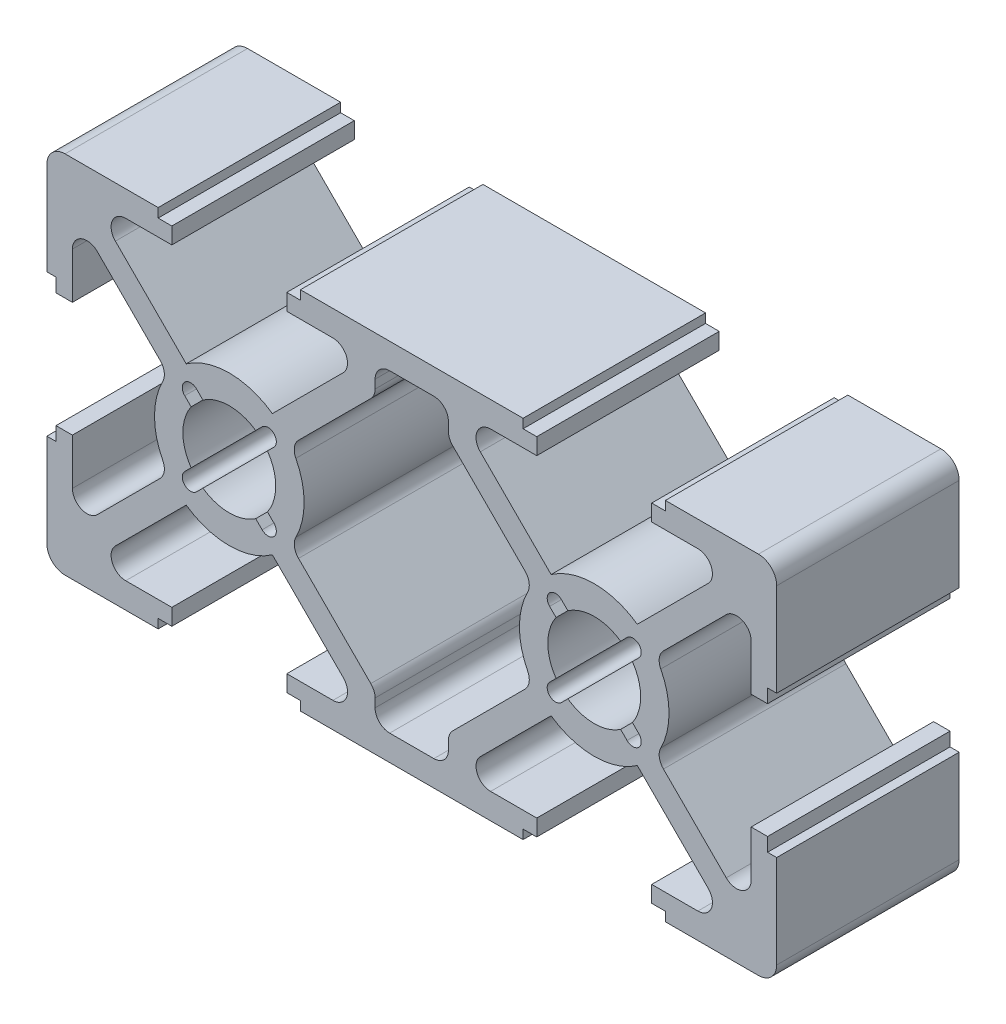
from build123d import *

# Parameters (mm, degrees)
Y_KSEKLIK_EKSTR_ZYON2_DEPTH = 10
RADYUS1_R                   = 0.8


with BuildPart() as part:
    # Çizim3 → Yükseklik-Ekstrüzyon2 (new body)
    with BuildSketch(Plane.XY):
        with BuildLine():
            Line((1, 0), (6.1, 0))
            Line((6.1, 0), (6.1, 0.5))
            Line((6.1, 0.5), (6.85, 0.5))
            Line((6.85, 0.5), (6.85, 1.4))
            Line((6.85, 1.4), (4.321320344, 1.4))
            ThreePointArc((4.321320344, 1.4), (3.582216718, 1.893853254), (3.755634919, 2.765685425))
            Line((3.755634919, 2.765685425), (7.638403375, 6.648453882))
            ThreePointArc((7.638403375, 6.648453882), (10, 5.9), (12.361596625, 6.648453882))
            Line((12.361596625, 6.648453882), (16.244365081, 2.765685425))
            ThreePointArc((16.244365081, 2.765685425), (16.417783282, 1.893853254), (15.678679656, 1.4))
            Line((15.678679656, 1.4), (13.15, 1.4))
            Line((13.15, 1.4), (13.15, 0.5))
            Line((13.15, 0.5), (13.9, 0.5))
            Line((13.9, 0.5), (13.9, 0))
            Line((13.9, 0), (26.1, 0))
            Line((26.1, 0), (26.1, 0.5))
            Line((26.1, 0.5), (26.85, 0.5))
            Line((26.85, 0.5), (26.85, 1.4))
            Line((26.85, 1.4), (24.321320344, 1.4))
            ThreePointArc((24.321320344, 1.4), (23.582216718, 1.893853254), (23.755634919, 2.765685425))
            Line((23.755634919, 2.765685425), (27.638403375, 6.648453882))
            ThreePointArc((27.638403375, 6.648453882), (30, 5.9), (32.361596625, 6.648453882))
            Line((32.361596625, 6.648453882), (36.244365081, 2.765685425))
            ThreePointArc((36.244365081, 2.765685425), (36.417783282, 1.893853254), (35.678679656, 1.4))
            Line((35.678679656, 1.4), (33.15, 1.4))
            Line((33.15, 1.4), (33.15, 0.5))
            Line((33.15, 0.5), (33.9, 0.5))
            Line((33.9, 0.5), (33.9, 0))
            Line((33.9, 0), (39, 0))
            ThreePointArc((39, 0), (39.707106781, 0.292893219), (40, 1))
            Line((40, 1), (40, 6.1))
            Line((40, 6.1), (39.5, 6.1))
            Line((39.5, 6.1), (39.5, 6.85))
            Line((39.5, 6.85), (38.6, 6.85))
            Line((38.6, 6.85), (38.6, 4.321320344))
            ThreePointArc((38.6, 4.321320344), (38.106146746, 3.582216718), (37.234314575, 3.755634919))
            Line((37.234314575, 3.755634919), (33.351546118, 7.638403375))
            ThreePointArc((33.351546118, 7.638403375), (34.1, 10), (33.351546118, 12.361596625))
            Line((33.351546118, 12.361596625), (37.234314575, 16.244365081))
            ThreePointArc((37.234314575, 16.244365081), (38.106146746, 16.417783282), (38.6, 15.678679656))
            Line((38.6, 15.678679656), (38.6, 13.15))
            Line((38.6, 13.15), (39.5, 13.15))
            Line((39.5, 13.15), (39.5, 13.9))
            Line((39.5, 13.9), (40, 13.9))
            Line((40, 13.9), (40, 19))
            ThreePointArc((40, 19), (39.707106781, 19.707106781), (39, 20))
            Line((39, 20), (33.9, 20))
            Line((33.9, 20), (33.9, 19.5))
            Line((33.9, 19.5), (33.15, 19.5))
            Line((33.15, 19.5), (33.15, 18.6))
            Line((33.15, 18.6), (35.678679656, 18.6))
            ThreePointArc((35.678679656, 18.6), (36.417783282, 18.106146746), (36.244365081, 17.234314575))
            Line((36.244365081, 17.234314575), (32.361596625, 13.351546118))
            ThreePointArc((32.361596625, 13.351546118), (30, 14.1), (27.638403375, 13.351546118))
            Line((27.638403375, 13.351546118), (23.755634919, 17.234314575))
            ThreePointArc((23.755634919, 17.234314575), (23.582216718, 18.106146746), (24.321320344, 18.6))
            Line((24.321320344, 18.6), (26.85, 18.6))
            Line((26.85, 18.6), (26.85, 19.5))
            Line((26.85, 19.5), (26.1, 19.5))
            Line((26.1, 19.5), (26.1, 20))
            Line((26.1, 20), (13.9, 20))
            Line((13.9, 20), (13.9, 19.5))
            Line((13.9, 19.5), (13.15, 19.5))
            Line((13.15, 19.5), (13.15, 18.6))
            Line((13.15, 18.6), (15.678679656, 18.6))
            ThreePointArc((15.678679656, 18.6), (16.417783282, 18.106146746), (16.244365081, 17.234314575))
            Line((16.244365081, 17.234314575), (12.361596625, 13.351546118))
            ThreePointArc((12.361596625, 13.351546118), (10, 14.1), (7.638403375, 13.351546118))
            Line((7.638403375, 13.351546118), (3.755634919, 17.234314575))
            ThreePointArc((3.755634919, 17.234314575), (3.582216718, 18.106146746), (4.321320344, 18.6))
            Line((4.321320344, 18.6), (6.85, 18.6))
            Line((6.85, 18.6), (6.85, 19.5))
            Line((6.85, 19.5), (6.1, 19.5))
            Line((6.1, 19.5), (6.1, 20))
            Line((6.1, 20), (1, 20))
            ThreePointArc((1, 20), (0.292893219, 19.707106781), (0, 19))
            Line((0, 19), (0, 13.9))
            Line((0, 13.9), (0.5, 13.9))
            Line((0.5, 13.9), (0.5, 13.15))
            Line((0.5, 13.15), (1.4, 13.15))
            Line((1.4, 13.15), (1.4, 15.678679656))
            ThreePointArc((1.4, 15.678679656), (1.893853254, 16.417783282), (2.765685425, 16.244365081))
            Line((2.765685425, 16.244365081), (6.648453882, 12.361596625))
            ThreePointArc((6.648453882, 12.361596625), (5.9, 10), (6.648453882, 7.638403375))
            Line((6.648453882, 7.638403375), (2.765685425, 3.755634919))
            ThreePointArc((2.765685425, 3.755634919), (1.893853254, 3.582216718), (1.4, 4.321320344))
            Line((1.4, 4.321320344), (1.4, 6.85))
            Line((1.4, 6.85), (0.5, 6.85))
            Line((0.5, 6.85), (0.5, 6.1))
            Line((0.5, 6.1), (0, 6.1))
            Line((0, 6.1), (0, 1))
            ThreePointArc((0, 1), (0.292893219, 0.292893219), (1, 0))
        make_face()
        with BuildLine():
            Line((21.210320913, 18.6), (18.789679087, 18.6))
            ThreePointArc((18.789679087, 18.6), (18.223993662, 18.365685425), (17.989679087, 17.8))
            Line((17.989679087, 17.8), (17.989679087, 17.331100443))
            ThreePointArc((17.989679087, 17.331100443), (17.928782713, 17.024953697), (17.755364512, 16.765415018))
            Line((17.755364512, 16.765415018), (13.351546118, 12.361596625))
            ThreePointArc((13.351546118, 12.361596625), (14.1, 10), (13.351546118, 7.638403375))
            Line((13.351546118, 7.638403375), (17.755364512, 3.234584982))
            ThreePointArc((17.755364512, 3.234584982), (17.928782713, 2.975046303), (17.989679087, 2.668899557))
            Line((17.989679087, 2.668899557), (17.989679087, 2.2))
            ThreePointArc((17.989679087, 2.2), (18.223993662, 1.634314575), (18.789679087, 1.4))
            Line((18.789679087, 1.4), (21.210320913, 1.4))
            ThreePointArc((21.210320913, 1.4), (21.776006338, 1.634314575), (22.010320913, 2.2))
            Line((22.010320913, 2.2), (22.010320913, 2.668899557))
            ThreePointArc((22.010320913, 2.668899557), (22.071217287, 2.975046303), (22.244635488, 3.234584982))
            Line((22.244635488, 3.234584982), (26.648453882, 7.638403375))
            ThreePointArc((26.648453882, 7.638403375), (25.9, 10), (26.648453882, 12.361596625))
            Line((26.648453882, 12.361596625), (22.244635488, 16.765415018))
            ThreePointArc((22.244635488, 16.765415018), (22.071217287, 17.024953697), (22.010320913, 17.331100443))
            Line((22.010320913, 17.331100443), (22.010320913, 17.8))
            ThreePointArc((22.010320913, 17.8), (21.776006338, 18.365685425), (21.210320913, 18.6))
        make_face(mode=Mode.SUBTRACT)
        with BuildLine():
            Line((8.201142588, 12.443783276), (8.552743846, 12.092182018))
            ThreePointArc((8.552743846, 12.092182018), (10, 12.543968548), (11.447256154, 12.092182018))
            Line((11.447256154, 12.092182018), (11.798857412, 12.443783276))
            ThreePointArc((11.798857412, 12.443783276), (12.443783276, 12.443783276), (12.443783276, 11.798857412))
            Line((12.443783276, 11.798857412), (12.092182018, 11.447256154))
            ThreePointArc((12.092182018, 11.447256154), (12.543968548, 10), (12.092182018, 8.552743846))
            Line((12.092182018, 8.552743846), (12.443783276, 8.201142588))
            ThreePointArc((12.443783276, 8.201142588), (12.443783276, 7.556216724), (11.798857412, 7.556216724))
            Line((11.798857412, 7.556216724), (11.447256154, 7.907817982))
            ThreePointArc((11.447256154, 7.907817982), (10, 7.456031452), (8.552743846, 7.907817982))
            Line((8.552743846, 7.907817982), (8.201142588, 7.556216724))
            ThreePointArc((8.201142588, 7.556216724), (7.556216724, 7.556216724), (7.556216724, 8.201142588))
            Line((7.556216724, 8.201142588), (7.907817982, 8.552743846))
            ThreePointArc((7.907817982, 8.552743846), (7.456031452, 10), (7.907817982, 11.447256154))
            Line((7.907817982, 11.447256154), (7.556216724, 11.798857412))
            ThreePointArc((7.556216724, 11.798857412), (7.556216724, 12.443783276), (8.201142588, 12.443783276))
        make_face(mode=Mode.SUBTRACT)
        with BuildLine():
            Line((27.907817982, 11.447256154), (27.556216724, 11.798857412))
            ThreePointArc((27.556216724, 11.798857412), (27.556216724, 12.443783276), (28.201142588, 12.443783276))
            Line((28.201142588, 12.443783276), (28.552743846, 12.092182018))
            ThreePointArc((28.552743846, 12.092182018), (30, 12.543968548), (31.447256154, 12.092182018))
            Line((31.447256154, 12.092182018), (31.798857412, 12.443783276))
            ThreePointArc((31.798857412, 12.443783276), (32.443783276, 12.443783276), (32.443783276, 11.798857412))
            Line((32.443783276, 11.798857412), (32.092182018, 11.447256154))
            ThreePointArc((32.092182018, 11.447256154), (32.543968548, 10), (32.092182018, 8.552743846))
            Line((32.092182018, 8.552743846), (32.443783276, 8.201142588))
            ThreePointArc((32.443783276, 8.201142588), (32.443783276, 7.556216724), (31.798857412, 7.556216724))
            Line((31.798857412, 7.556216724), (31.447256154, 7.907817982))
            ThreePointArc((31.447256154, 7.907817982), (30, 7.456031452), (28.552743846, 7.907817982))
            Line((28.552743846, 7.907817982), (28.201142588, 7.556216724))
            ThreePointArc((28.201142588, 7.556216724), (27.556216724, 7.556216724), (27.556216724, 8.201142588))
            Line((27.556216724, 8.201142588), (27.907817982, 8.552743846))
            ThreePointArc((27.907817982, 8.552743846), (27.456031452, 10), (27.907817982, 11.447256154))
        make_face(mode=Mode.SUBTRACT)
    extrude(amount=Y_KSEKLIK_EKSTR_ZYON2_DEPTH)

    # Radyus1
    radyus1_edges = [part.edges().sort_by_distance(p)[0] for p in [
        (6.648453882, 7.638403375, 5),
        (6.648453882, 12.361596625, 5),
        (33.351546118, 12.361596625, 5),
        (33.351546118, 7.638403375, 5),
        (13.351546118, 12.361596625, 5),
        (13.351546118, 7.638403375, 5),
        (26.648453882, 7.638403375, 5),
        (26.648453882, 12.361596625, 5),
    ]]
    fillet(radyus1_edges, radius=RADYUS1_R)


solid = part.part
